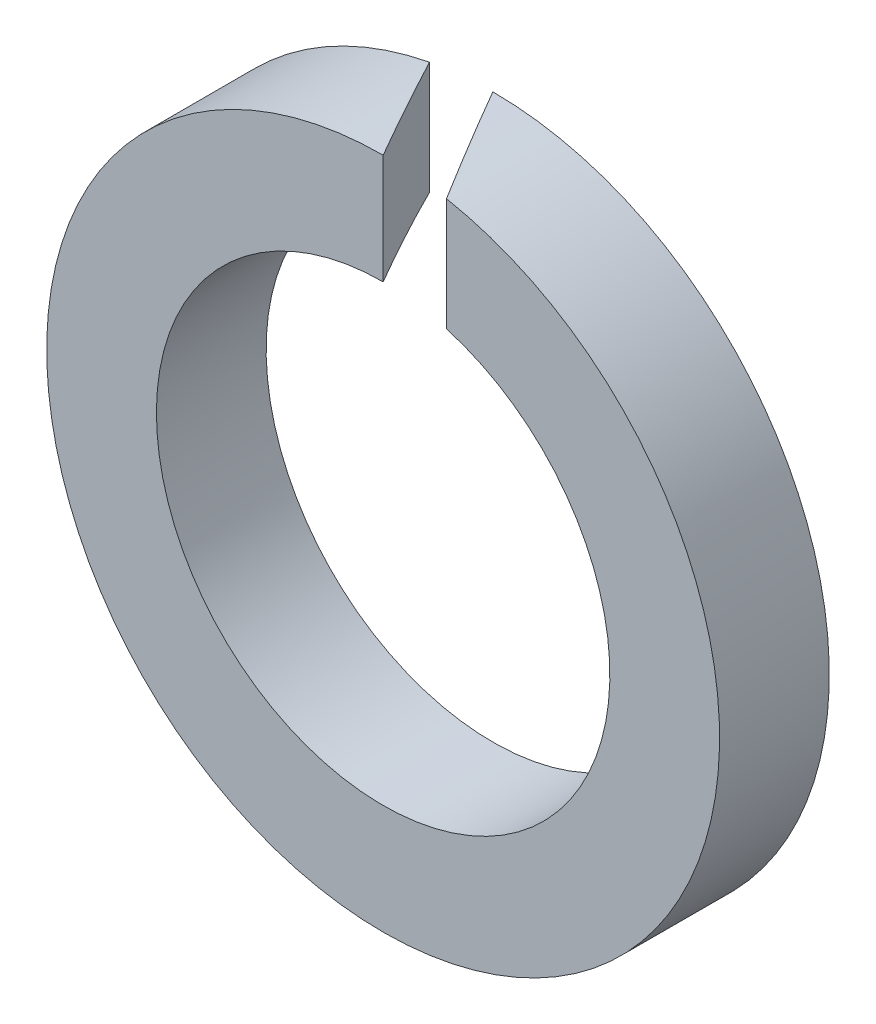
from build123d import *

# Parameters (mm, degrees)
SKETCH_1_R          = 6.44
SKETCH_1_R_2        = 4.34
EXTRUDE_1_DEPTH     = 2.1
CUT_EXTRUDE_1_DEPTH = 7.44


with BuildPart() as part:
    # 草图1 → 凸台-拉伸1 (new body)
    with BuildSketch(Plane.XY):
        Circle(SKETCH_1_R)
        Circle(SKETCH_1_R_2, mode=Mode.SUBTRACT)
    extrude(amount=EXTRUDE_1_DEPTH)

    # 草图2 → 切除-拉伸1 (cut, through all)
    with BuildSketch(Plane(origin=(0, 0, 0), x_dir=(1, 0, 0), z_dir=(0, 1, 0))):
        Polygon((0, 0), (1.212435565, -2.1), (0, -2.1), (-1.212435565, 0), align=None)
    extrude(amount=CUT_EXTRUDE_1_DEPTH, mode=Mode.SUBTRACT)


solid = part.part
